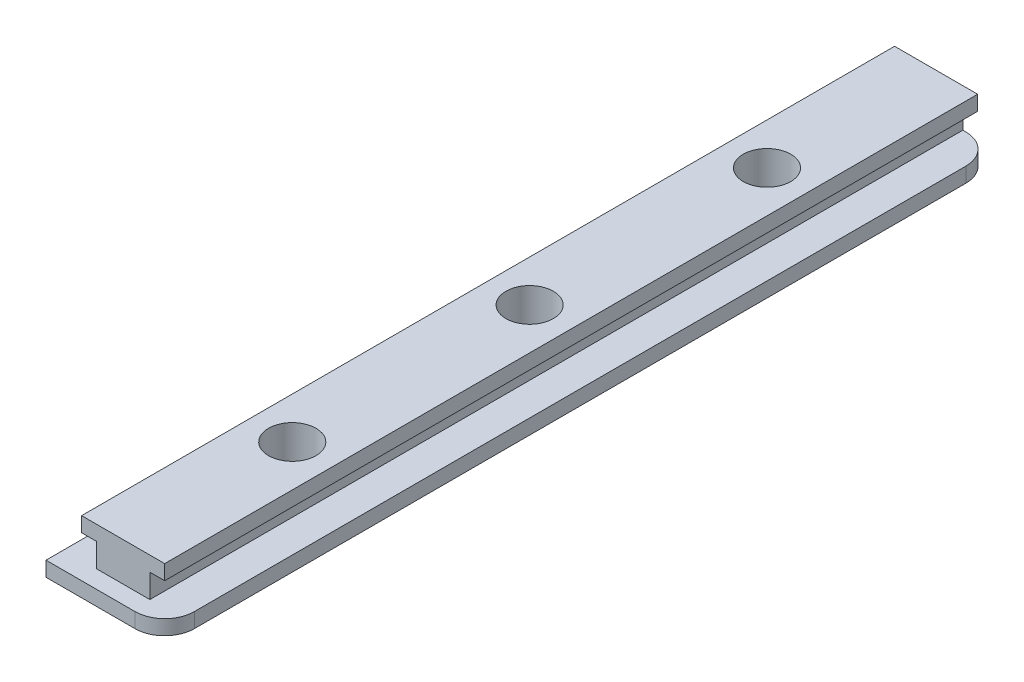
from build123d import *

# Parameters (mm, degrees)
BOSS_EXTRUDE2_DEPTH = 68.5
SKETCH4_R           = 4
CUT_EXTRUDE1_DEPTH  = 6
SKETCH5_R           = 2.5
CUT_EXTRUDE2_DEPTH  = 4
SKETCH7_W           = 20
SKETCH7_H           = 2.5
BOSS_EXTRUDE6_DEPTH = 3
FILLET2_R           = 5


with BuildPart() as part:
    # Sketch1 → Boss-Extrude2 (new body, symmetric)
    with BuildSketch(Plane.XY):
        Polygon((-7, 4.5), (7, 4.5), (7, 2), (4.5, 2), (4.5, -2), (10, -2), (10, -4.5), (-10, -4.5), (-10, -2), (-4.5, -2), (-4.5, 2), (-7, 2), align=None)
    extrude(amount=BOSS_EXTRUDE2_DEPTH, both=True)

    # Sketch4 → Cut-Extrude1 (cut)
    with BuildSketch(Plane(origin=(0, 4.5, 0), x_dir=(1, 0, 0), z_dir=(0, 1, 0))):
        Circle(SKETCH4_R)
        with Locations((0, 40)):
            Circle(SKETCH4_R)
        with Locations((0, -40)):
            Circle(SKETCH4_R)
    extrude(amount=-CUT_EXTRUDE1_DEPTH, mode=Mode.SUBTRACT)

    # Sketch5 → Cut-Extrude2 (cut)
    with BuildSketch(Plane(origin=(0, -1.5, 0), x_dir=(1, 0, 0), z_dir=(0, 1, 0))):
        with Locations((0, 40)):
            Circle(SKETCH5_R)
        Circle(SKETCH5_R)
        with Locations((0, -40)):
            Circle(SKETCH5_R)
    extrude(amount=-CUT_EXTRUDE2_DEPTH, mode=Mode.SUBTRACT)

    # Sketch7 → Boss-Extrude6 (add)
    with BuildSketch(Plane.XY.offset(68.5)):
        with Locations((0, -3.25)):
            Rectangle(SKETCH7_W, SKETCH7_H)
    extrude(amount=BOSS_EXTRUDE6_DEPTH)

    # Fillet2
    fillet2_edges = [part.edges().sort_by_distance(p)[0] for p in [
        (10, -3.25, -68.5),
        (10, -3.25, 71.5),
    ]]
    fillet(fillet2_edges, radius=FILLET2_R)


solid = part.part
